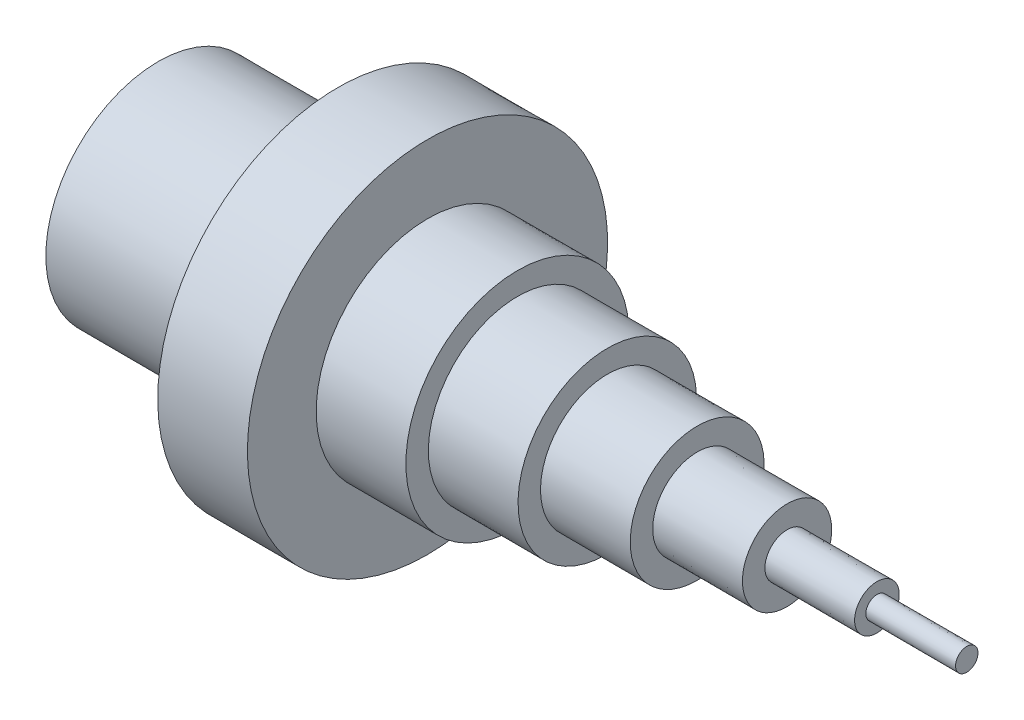
from build123d import *


with BuildPart() as part:
    # Sketch1 → Revolve1 (revolve)
    with BuildSketch(Plane.XY):
        Polygon((0, 0), (0, 25), (40, 25), (40, 40), (60, 40), (60, 24.719643467), (80, 24.719643467), (80, 19.719643467), (100, 19.719643467), (100, 14.719643467), (120, 14.719643467), (120, 9.719643467), (140, 9.719643467), (140, 4.719643467), (160, 4.719643467), (160, 2.219643467), (180, 2.219643467), (179.999781667, -0.280356523), align=None)
    revolve(axis=Axis((0, 0, 0), (0.999998787, -0.001557536, 0)))


solid = part.part
